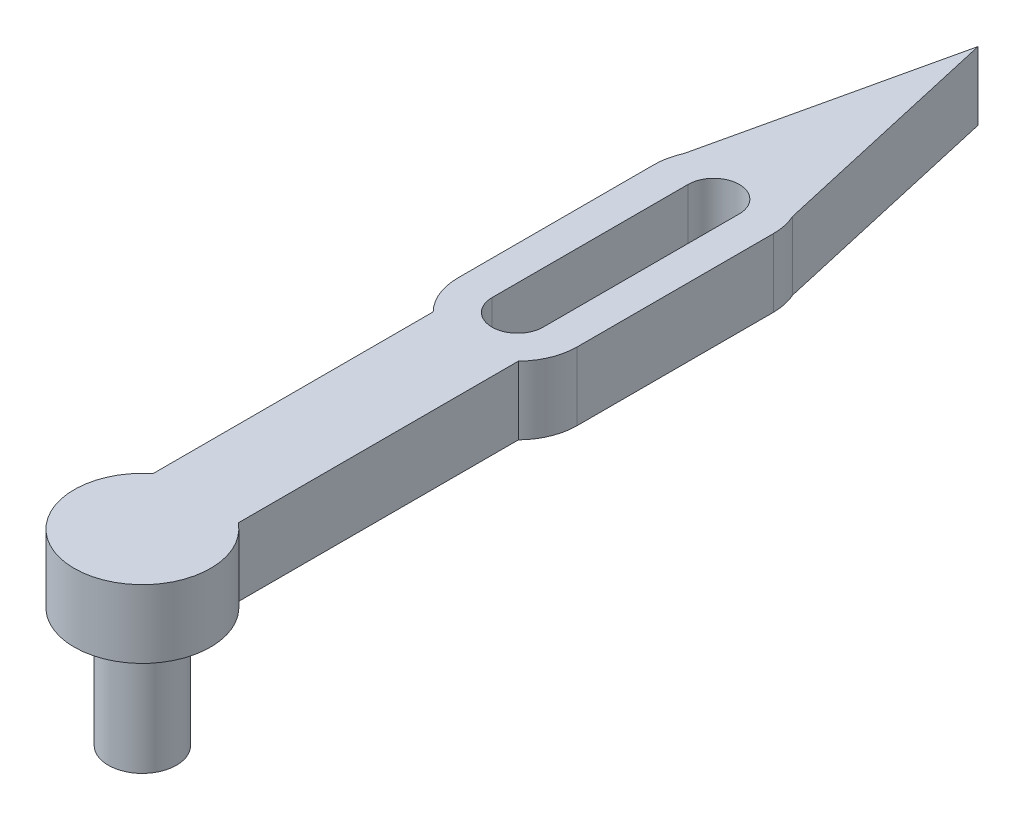
from build123d import *

# Parameters (mm, degrees)
BOSS_EXTRUDE1_DEPTH = 8
SKETCH3_R           = 4
BOSS_EXTRUDE2_DEPTH = 14


with BuildPart() as part:
    # Sketch2 → Boss-Extrude1 (new body)
    with BuildSketch(Plane(origin=(0, 0, 0), x_dir=(1, 0, 0), z_dir=(0, 1, 0))):
        with BuildLine():
            Line((-5, 6.244997998), (-5, 39.101020514))
            ThreePointArc((-5, 39.101020514), (-6.480740698, 41.354248689), (-7, 44))
            Line((-7, 44), (-7, 67))
            ThreePointArc((-7, 67), (-6.84274311, 68.475420866), (-6.378038076, 69.884550276))
            Line((-6.378038076, 69.884550276), (0, 98))
            Line((0, 98), (6.378038076, 69.884550276))
            ThreePointArc((6.378038076, 69.884550276), (6.84274311, 68.475420866), (7, 67))
            Line((7, 67), (7, 44))
            ThreePointArc((7, 44), (6.480740698, 41.354248689), (5, 39.101020514))
            Line((5, 39.101020514), (5, 6.244997998))
            ThreePointArc((5, 6.244997998), (0, -8), (-5, 6.244997998))
        make_face()
        with BuildLine():
            Line((-3, 67), (-3, 44))
            ThreePointArc((-3, 44), (0, 41), (3, 44))
            Line((3, 44), (3, 67))
            ThreePointArc((3, 67), (0, 70), (-3, 67))
        make_face(mode=Mode.SUBTRACT)
    extrude(amount=BOSS_EXTRUDE1_DEPTH)

    # Sketch3 → Boss-Extrude2 (add)
    with BuildSketch(Plane.XZ):
        Circle(SKETCH3_R)
    extrude(amount=BOSS_EXTRUDE2_DEPTH)


solid = part.part
